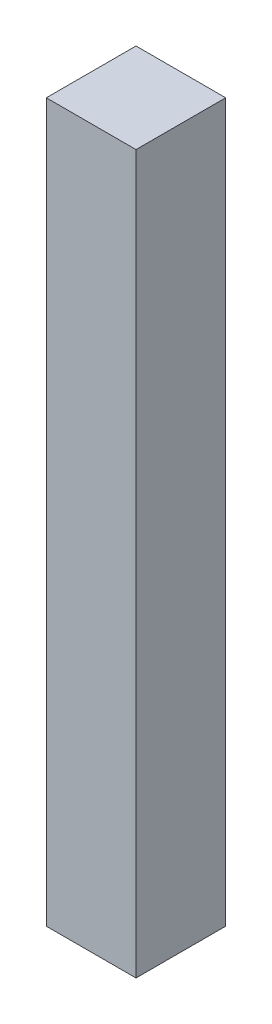
from build123d import *

# Parameters (mm, degrees)
SKETCH2_W           = 3.175
SKETCH2_H           = 25.4
BOSS_EXTRUDE1_DEPTH = 3.175


with BuildPart() as part:
    # Sketch2 → Boss-Extrude1 (new body)
    with BuildSketch(Plane.XY):
        Rectangle(SKETCH2_W, SKETCH2_H)
    extrude(amount=BOSS_EXTRUDE1_DEPTH)


solid = part.part
